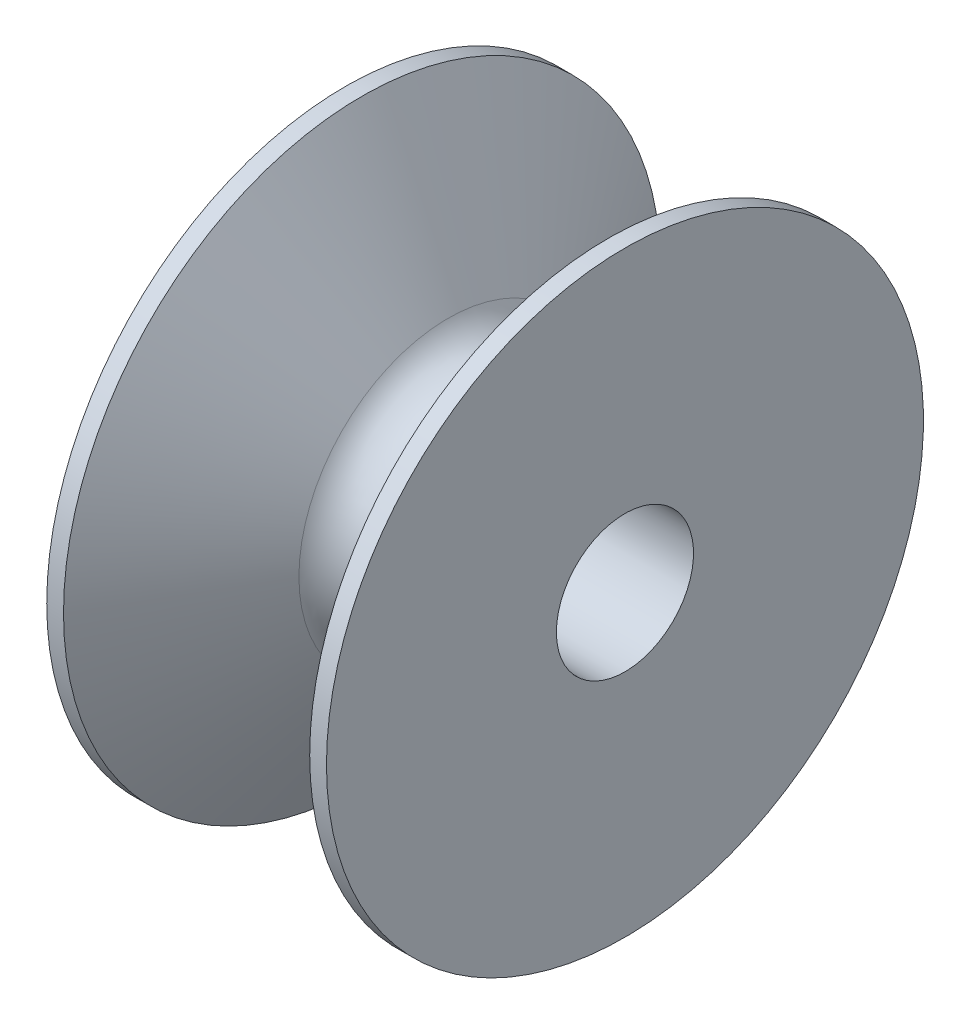
from build123d import *


with BuildPart() as part:
    # Sketch1 → Revolve1 (revolve)
    with BuildSketch(Plane.XY):
        with BuildLine():
            Line((0, 2.5527), (10.414, 2.5527))
            Line((10.414, 2.5527), (10.414, 11.1125))
            Line((10.414, 11.1125), (9.789717762, 11.1125))
            Line((9.789717762, 11.1125), (6.581815329, 5.55625))
            ThreePointArc((6.581815329, 5.55625), (5.207, 4.7625), (3.832184671, 5.55625))
            Line((3.832184671, 5.55625), (0.624282238, 11.1125))
            Line((0.624282238, 11.1125), (0, 11.1125))
            Line((0, 11.1125), (0, 2.5527))
        make_face()
    revolve(axis=Axis((0, 0, 0), (1, 0, 0)))


solid = part.part
